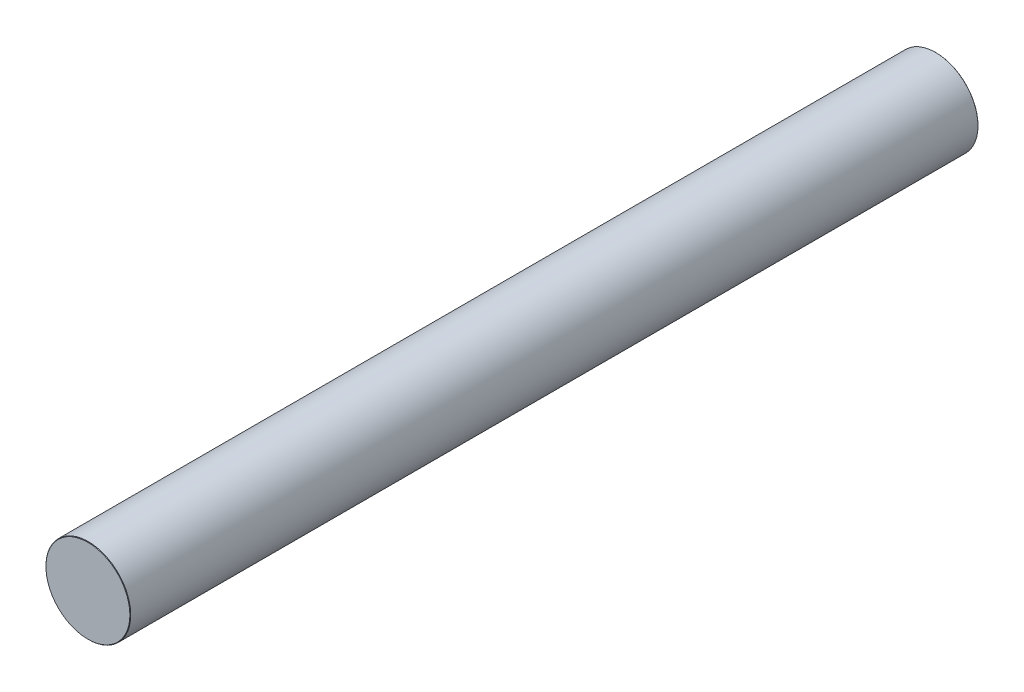
from build123d import *

# Parameters (mm, degrees)
SKETCH_1_R      = 10
EXTRUDE_1_DEPTH = 200
CHAMFER_1_SIZE  = 0.1


with BuildPart() as part:
    # Эскиз1 → Бобышка-Вытянуть1 (new body)
    with BuildSketch(Plane.XY):
        Circle(SKETCH_1_R)
    extrude(amount=EXTRUDE_1_DEPTH)

    # Фаска1
    chamfer_1_edges = [part.edges().sort_by_distance(p)[0] for p in [
        (-10, 0, 0),
        (-10, 0, 200),
    ]]
    chamfer(chamfer_1_edges, length=CHAMFER_1_SIZE)


solid = part.part
